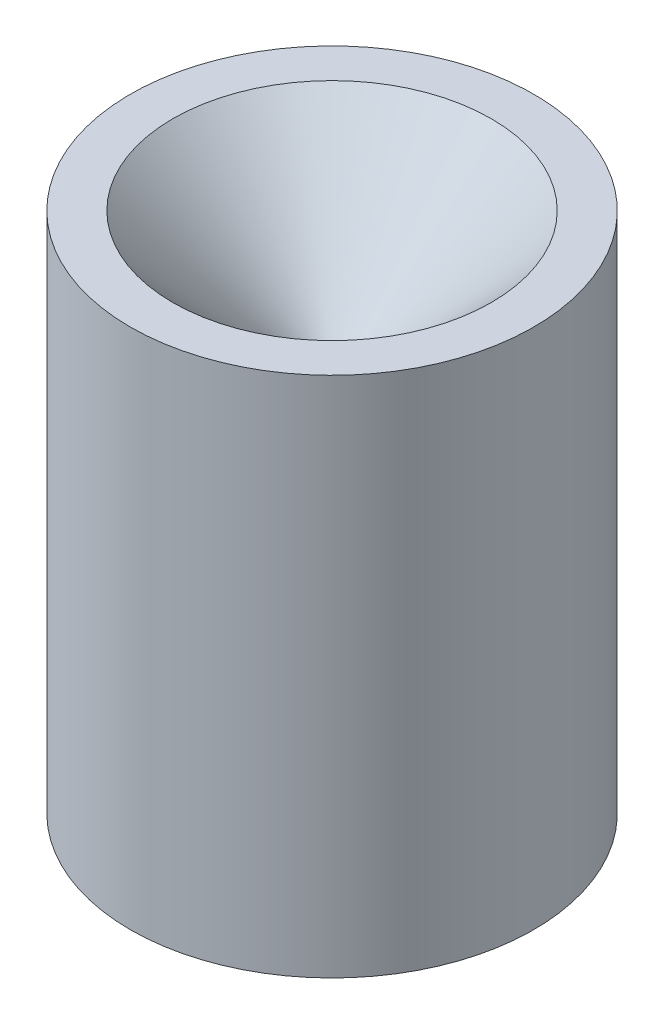
from build123d import *


with BuildPart() as part:
    # Sketch5 → Revolve2 (revolve)
    with BuildSketch(Plane.XY):
        with BuildLine():
            ThreePointArc((6.647472776, -0.637932427), (6.425260177, 0.01668478), (6.35, 0.703880554))
            Line((6.35, 0.703880554), (6.35, 5.034871939))
            ThreePointArc((6.35, 5.034871939), (6.591682484, 6.249891837), (7.27993597, 7.27993597))
            Line((7.27993597, 7.27993597), (26.9875, 26.9875))
            Line((26.9875, 26.9875), (30.1625, 26.9875))
            Line((30.1625, 26.9875), (30.1625, -51.066071045))
            Line((30.1625, -51.066071045), (6.647472776, -0.637932427))
        make_face()
        with BuildLine():
            ThreePointArc((3.175, 5.034871939), (3.416682484, 6.249891837), (4.10493597, 7.27993597))
            Line((4.10493597, 7.27993597), (23.8125, 26.9875))
            Line((23.8125, 26.9875), (26.9875, 26.9875))
            Line((26.9875, 26.9875), (7.27993597, 7.27993597))
            ThreePointArc((7.27993597, 7.27993597), (6.591682484, 6.249891837), (6.35, 5.034871939))
            Line((6.35, 5.034871939), (6.35, 0.703880554))
            ThreePointArc((6.35, 0.703880554), (6.425260177, 0.01668478), (6.647472776, -0.637932427))
            Line((6.647472776, -0.637932427), (30.1625, -51.066071045))
            Line((30.1625, -51.066071045), (26.9875, -51.066071045))
            Line((26.9875, -51.066071045), (3.472472776, -0.637932427))
            ThreePointArc((3.472472776, -0.637932427), (3.250260177, 0.01668478), (3.175, 0.703880554))
            Line((3.175, 0.703880554), (3.175, 5.034871939))
        make_face()
    revolve(axis=Axis((0, 0, 0), (0, -1, 0)))


solid = part.part
